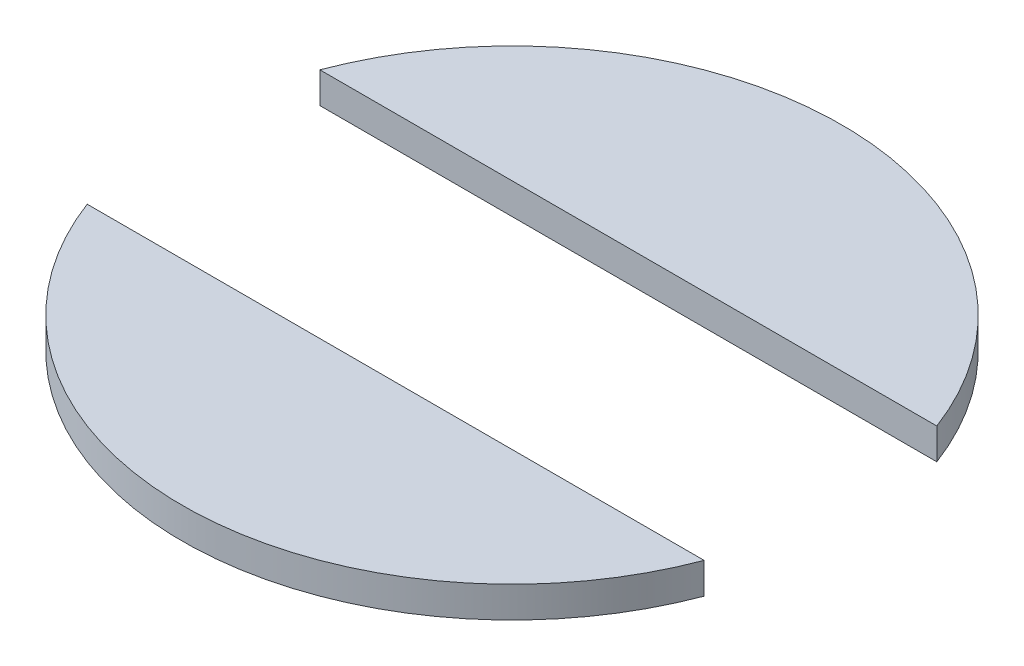
from build123d import *

# Parameters (mm, degrees)
BOSS_EXTRUDE1_DEPTH   = 0.2
BOSS_EXTRUDE1_2_DEPTH = 0.2


with BuildPart() as part:
    # Sketch1 → Boss-Extrude1 (new body)
    with BuildSketch(Plane(origin=(0, 0, 0), x_dir=(1, 0, 0), z_dir=(0, 1, 0))):
        with BuildLine():
            ThreePointArc((-1.988246715, -0.75), (0, -2.125), (1.988246715, -0.75))
            Line((1.988246715, -0.75), (-1.988246715, -0.75))
        make_face()
    extrude(amount=BOSS_EXTRUDE1_DEPTH)


with BuildPart() as body_2:
    # Sketch1 → Boss-Extrude1 2 (new body)
    with BuildSketch(Plane(origin=(0, 0, 0), x_dir=(1, 0, 0), z_dir=(0, 1, 0))):
        with BuildLine():
            Line((-1.988246715, 0.75), (1.988246715, 0.75))
            ThreePointArc((1.988246715, 0.75), (0, 2.125), (-1.988246715, 0.75))
        make_face()
    extrude(amount=BOSS_EXTRUDE1_2_DEPTH)


solid = Compound([part.part, body_2.part])
